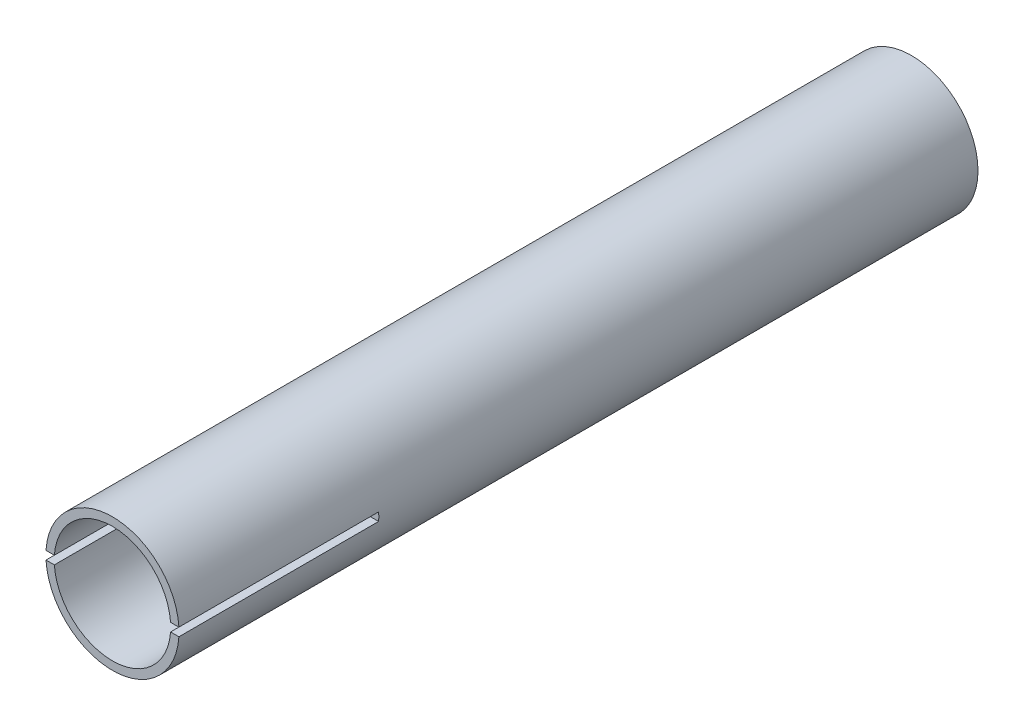
from build123d import *

# Parameters (mm, degrees)
SKETCH1_R                      = 12.7
SKETCH1_R_2                    = 11.1125
EXTRUDE1_DEPTH                 = 152.4
CUT_EXTRUDE1_REACH             = 14.7
SKETCH2_W                      = 38.1
SKETCH2_H                      = 1.5875
CUT_EXTRUDE1_DIRECTION_2_REACH = 14.7


with BuildPart() as part:
    # Sketch1 → Extrude1 (new body)
    with BuildSketch(Plane.XY):
        Circle(SKETCH1_R)
        Circle(SKETCH1_R_2, mode=Mode.SUBTRACT)
    extrude(amount=EXTRUDE1_DEPTH)

    # Sketch2 → Cut-Extrude1 (cut, up to next)
    with BuildSketch(Plane(origin=(0, 0, 0), x_dir=(0, 0, -1), z_dir=(1, 0, 0)), mode=Mode.PRIVATE) as cut_extrude1_sk1:
        with Locations((-133.35, 0)):
            Rectangle(SKETCH2_W, SKETCH2_H)
    cut_extrude1_tool1 = extrude(cut_extrude1_sk1.sketch, amount=-CUT_EXTRUDE1_REACH, mode=Mode.PRIVATE) & part.part
    add(cut_extrude1_tool1.solids().sort_by_distance((0, 0, 133.35))[0], mode=Mode.SUBTRACT)

    # Sketch2 → Cut-Extrude1 direction 2 (cut, up to next)
    with BuildSketch(Plane(origin=(0, 0, 0), x_dir=(0, 0, -1), z_dir=(1, 0, 0)), mode=Mode.PRIVATE) as cut_extrude1_direction_2_sk1:
        with Locations((-133.35, 0)):
            Rectangle(SKETCH2_W, SKETCH2_H)
    cut_extrude1_direction_2_tool1 = extrude(cut_extrude1_direction_2_sk1.sketch, amount=CUT_EXTRUDE1_DIRECTION_2_REACH, mode=Mode.PRIVATE) & part.part
    add(cut_extrude1_direction_2_tool1.solids().sort_by_distance((0, 0, 133.35))[0], mode=Mode.SUBTRACT)


solid = part.part
